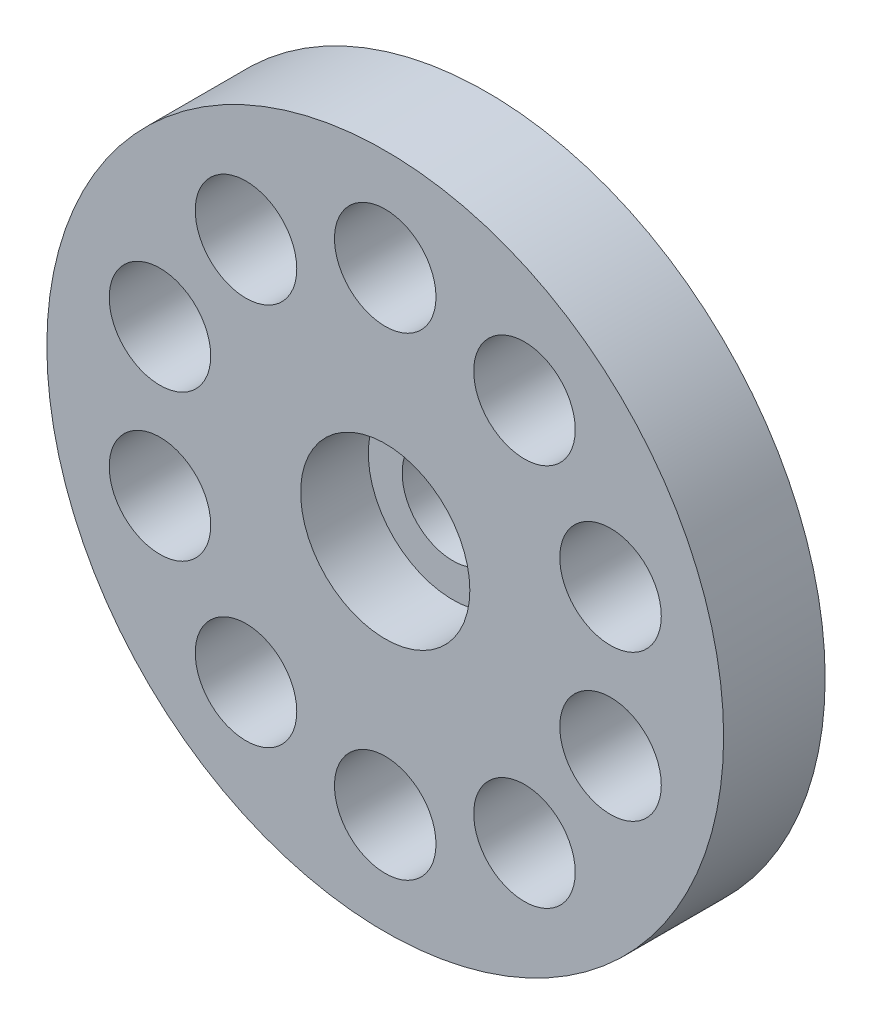
from build123d import *

# Parameters (mm, degrees)
SKETCH1_R           = 10
BOSS_EXTRUDE1_DEPTH = 3
SKETCH1_6_R         = 1.5
CUT_EXTRUDE2_DEPTH  = 15.456832295
SKETCH1_7_R         = 1.5
CUT_EXTRUDE3_DEPTH  = 15.456832295
SKETCH3_R           = 2.5
CUT_EXTRUDE5_DEPTH  = 2


with BuildPart() as part:
    # Sketch1 → Boss-Extrude1 (new body)
    with BuildSketch(Plane.XY):
        Circle(SKETCH1_R)
    extrude(amount=BOSS_EXTRUDE1_DEPTH)

    # Sketch1_6 → Cut-Extrude2 (cut, through all)
    with BuildSketch(Plane.XY):
        Circle(SKETCH1_6_R)
    extrude(amount=CUT_EXTRUDE2_DEPTH, mode=Mode.SUBTRACT)

    # Sketch1_7 → Cut-Extrude3 (cut, through all)
    with BuildSketch(Plane.XY):
        with Locations((0, -7)):
            Circle(SKETCH1_7_R)
        with Locations((-4.114496766, -5.663118961)):
            Circle(SKETCH1_7_R)
        with Locations((-6.657395614, -2.163118961)):
            Circle(SKETCH1_7_R)
        with Locations((-6.657395614, 2.163118961)):
            Circle(SKETCH1_7_R)
        with Locations((-4.114496766, 5.663118961)):
            Circle(SKETCH1_7_R)
        with Locations((0, 7)):
            Circle(SKETCH1_7_R)
        with Locations((4.114496766, 5.663118961)):
            Circle(SKETCH1_7_R)
        with Locations((6.657395614, 2.163118961)):
            Circle(SKETCH1_7_R)
        with Locations((6.657395614, -2.163118961)):
            Circle(SKETCH1_7_R)
        with Locations((4.114496766, -5.663118961)):
            Circle(SKETCH1_7_R)
    extrude(amount=CUT_EXTRUDE3_DEPTH, mode=Mode.SUBTRACT)

    # Sketch3 → Cut-Extrude5 (cut)
    with BuildSketch(Plane.XY.offset(3)):
        Circle(SKETCH3_R)
    extrude(amount=-CUT_EXTRUDE5_DEPTH, mode=Mode.SUBTRACT)


solid = part.part
